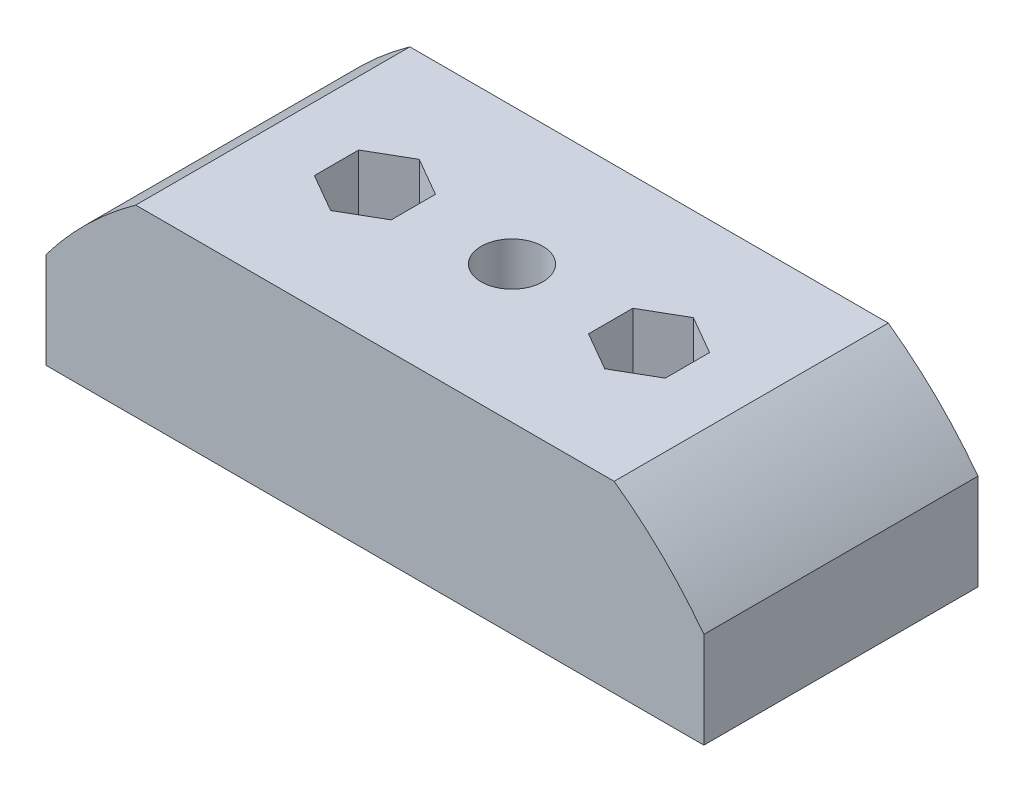
from build123d import *

# Parameters (mm, degrees)
BOSS_EXTRUDE1_DEPTH = 10
CUT_EXTRUDE1_REACH  = 15.4
SKETCH2_R           = 2.25
SKETCH2_R_2         = 1.6
CUT_EXTRUDE2_DEPTH  = 7.4
CUT_EXTRUDE3_DEPTH  = 7.4


with BuildPart() as part:
    # Sketch1 → Boss-Extrude1 (new body, symmetric)
    with BuildSketch(Plane.XY):
        with BuildLine():
            Line((17.453939383, -30.6), (-17.453939383, -30.6))
            ThreePointArc((-17.453939383, -30.6), (-20.972536151, -33.54882923), (-24, -37))
            Line((-24, -37), (-24, -44))
            Line((-24, -44), (24, -44))
            Line((24, -44), (24, -37))
            ThreePointArc((24, -37), (20.972536151, -33.54882923), (17.453939383, -30.6))
        make_face()
    extrude(amount=BOSS_EXTRUDE1_DEPTH, both=True)

    # Sketch2 → Cut-Extrude1 (cut, up to next)
    with BuildSketch(Plane(origin=(0, -30.6, 0), x_dir=(1, 0, 0), z_dir=(0, 1, 0)), mode=Mode.PRIVATE) as cut_extrude1_sk1:
        Circle(SKETCH2_R)
    cut_extrude1_tool1 = extrude(cut_extrude1_sk1.sketch, amount=-CUT_EXTRUDE1_REACH, mode=Mode.PRIVATE) & part.part
    add(cut_extrude1_tool1.solids().sort_by_distance((0, -30.6, 0))[0], mode=Mode.SUBTRACT)
    # Sketch2 → Cut-Extrude1 (cut, up to next)
    with BuildSketch(Plane(origin=(0, -30.6, 0), x_dir=(1, 0, 0), z_dir=(0, 1, 0)), mode=Mode.PRIVATE) as cut_extrude1_sk2:
        with Locations((-10, 0)):
            Circle(SKETCH2_R_2)
    cut_extrude1_tool2 = extrude(cut_extrude1_sk2.sketch, amount=-CUT_EXTRUDE1_REACH, mode=Mode.PRIVATE) & part.part
    add(cut_extrude1_tool2.solids().sort_by_distance((-10, -30.6, 0))[0], mode=Mode.SUBTRACT)
    # Sketch2 → Cut-Extrude1 (cut, up to next)
    with BuildSketch(Plane(origin=(0, -30.6, 0), x_dir=(1, 0, 0), z_dir=(0, 1, 0)), mode=Mode.PRIVATE) as cut_extrude1_sk3:
        with Locations((10, 0)):
            Circle(SKETCH2_R_2)
    cut_extrude1_tool3 = extrude(cut_extrude1_sk3.sketch, amount=-CUT_EXTRUDE1_REACH, mode=Mode.PRIVATE) & part.part
    add(cut_extrude1_tool3.solids().sort_by_distance((10, -30.6, 0))[0], mode=Mode.SUBTRACT)

    # Sketch3 → Cut-Extrude2 (cut)
    with BuildSketch(Plane(origin=(0, -30.6, 0), x_dir=(1, 0, 0), z_dir=(0, 1, 0))):
        Polygon((-10, -3.233161507), (-7.2, -1.616580754), (-7.2, 1.616580754), (-10, 3.233161507), (-12.8, 1.616580754), (-12.8, -1.616580754), align=None)
        Polygon((10, -3.233161507), (7.2, -1.616580754), (7.2, 1.616580754), (10, 3.233161507), (12.8, 1.616580754), (12.8, -1.616580754), align=None)
    extrude(amount=-CUT_EXTRUDE2_DEPTH, mode=Mode.SUBTRACT)

    # Sketch4 → Cut-Extrude3 (cut)
    with BuildSketch(Plane.XZ.offset(44)):
        Polygon((0, -4.041451884), (3.5, -2.020725942), (3.5, 2.020725942), (0, 4.041451884), (-3.5, 2.020725942), (-3.5, -2.020725942), align=None)
    extrude(amount=-CUT_EXTRUDE3_DEPTH, mode=Mode.SUBTRACT)


solid = part.part
